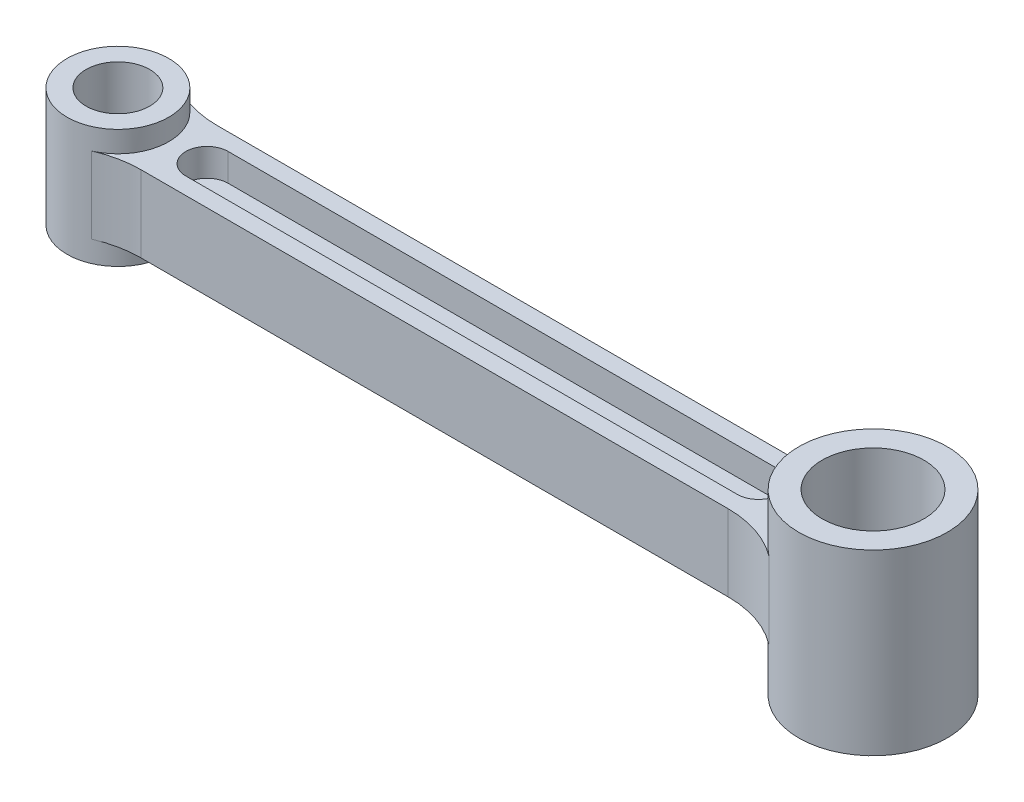
from build123d import *

# Parameters (mm, degrees)
SKETCH1_R           = 12
SKETCH1_R_2         = 7.5
BOSS_EXTRUDE1_DEPTH = 14
SKETCH3_R           = 17.5
SKETCH3_R_2         = 12
BOSS_EXTRUDE2_DEPTH = 21
BOSS_EXTRUDE3_DEPTH = 9
CUT_EXTRUDE1_DEPTH  = 6.5
FILLET1_R           = 24


with BuildPart() as part:
    # Sketch1 → Boss-Extrude1 (new body, symmetric)
    with BuildSketch(Plane(origin=(0, 0, 0), x_dir=(1, 0, 0), z_dir=(0, 1, 0))):
        Circle(SKETCH1_R)
        Circle(SKETCH1_R_2, mode=Mode.SUBTRACT)
    extrude(amount=BOSS_EXTRUDE1_DEPTH, both=True)



with BuildPart() as body_2:
    # Sketch3 → Boss-Extrude2 (new body, symmetric)
    with BuildSketch(Plane(origin=(0, 0, 0), x_dir=(1, 0, 0), z_dir=(0, 1, 0))):
        with Locations((178, 0)):
            Circle(SKETCH3_R)
        with Locations((178, 0)):
            Circle(SKETCH3_R_2, mode=Mode.SUBTRACT)
    extrude(amount=BOSS_EXTRUDE2_DEPTH, both=True)


with BuildPart() as part_1:
    add(part.part)

    add(body_2.part)  # Boss-Extrude3 merges body 2
    # Sketch4 → Boss-Extrude3 (add, symmetric)
    with BuildSketch(Plane(origin=(0, 0, 0), x_dir=(1, 0, 0), z_dir=(0, 1, 0))):
        with BuildLine():
            Line((7.937253933, 9), (162.99166898, 9))
            ThreePointArc((162.99166898, 9), (160.5, 0), (162.99166898, -9))
            Line((162.99166898, -9), (7.937253933, -9))
            ThreePointArc((7.937253933, -9), (12, 0), (7.937253933, 9))
        make_face()
    extrude(amount=BOSS_EXTRUDE3_DEPTH, both=True)

    # Sketch5 → Cut-Extrude1 (cut)
    with BuildSketch(Plane(origin=(0, 9, 0), x_dir=(1, 0, 0), z_dir=(0, 1, 0))):
        with BuildLine():
            Line((21, 5), (151, 5))
            ThreePointArc((151, 5), (156, 0), (151, -5))
            Line((151, -5), (21, -5))
            ThreePointArc((21, -5), (16, 0), (21, 5))
        make_face()
    cut_extrude1 = extrude(amount=-CUT_EXTRUDE1_DEPTH, mode=Mode.SUBTRACT)

    # Mirror1: Cut-Extrude1 across plane
    add(cut_extrude1.mirror(Plane.ZX), mode=Mode.SUBTRACT)

    # Fillet1
    fillet1_edges = [part_1.edges().sort_by_distance(p)[0] for p in [
        (7.937253933, 0, -9),
        (7.937253933, 0, 9),
        (162.99166898, 0, 9),
        (162.99166898, 0, -9),
    ]]
    fillet(fillet1_edges, radius=FILLET1_R)


solid = part_1.part
